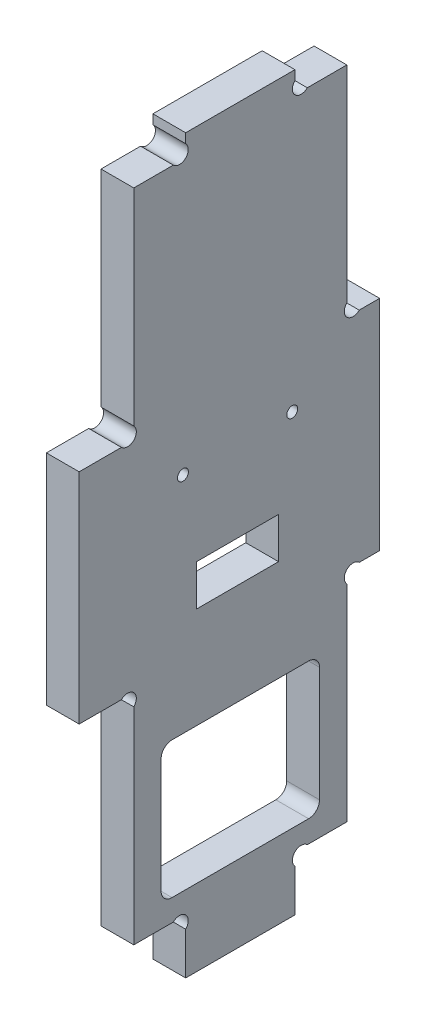
from build123d import *

# Parameters (mm, degrees)
EXTRUSION1_DEPTH        = 6
ESQUISSE2_R             = 1
ESQUISSE2_W             = 29
ESQUISSE2_H             = 25
ENL_V_MAT_EXTRU_1_DEPTH = 7
CONG_1_R                = 2
ESQUISSE3_W             = 15
ESQUISSE3_H             = 7.5
ENL_V_MAT_EXTRU_2_DEPTH = 7


with BuildPart() as part:
    # Esquisse1 → Extrusion1 (new body)
    with BuildSketch(Plane(origin=(0, 0, 0), x_dir=(0, 0, -1), z_dir=(1, 0, 0))):
        with BuildLine():
            Line((19.5, 7.7372583), (19.5, 0))
            Line((19.5, 0), (39.5, 0))
            Line((39.5, 0), (39.5, 7.7372583))
            ThreePointArc((39.5, 7.7372583), (39.5, 10), (41.7627417, 10))
            Line((41.7627417, 10), (49, 10))
            Line((49, 10), (49, 47.7372583))
            ThreePointArc((49, 47.7372583), (49, 50), (51.2627417, 50))
            Line((51.2627417, 50), (55, 50))
            Line((55, 50), (55, 90))
            Line((55, 90), (51.2627417, 90))
            ThreePointArc((51.2627417, 90), (49, 90), (49, 92.2627417))
            Line((49, 92.2627417), (49, 130))
            Line((49, 130), (41.7627417, 130))
            ThreePointArc((41.7627417, 130), (39.5, 130), (39.5, 132.2627417))
            Line((39.5, 132.2627417), (39.5, 134))
            Line((39.5, 134), (19.5, 134))
            Line((19.5, 134), (19.5, 132.2627417))
            ThreePointArc((19.5, 132.2627417), (19.5, 130), (17.2372583, 130))
            Line((17.2372583, 130), (10, 130))
            Line((10, 130), (10, 92.2627417))
            ThreePointArc((10, 92.2627417), (10, 90), (7.7372583, 90))
            Line((7.7372583, 90), (0, 90))
            Line((0, 90), (0, 50))
            Line((0, 50), (7.7372583, 50))
            ThreePointArc((7.7372583, 50), (10, 50), (10, 47.7372583))
            Line((10, 47.7372583), (10, 10))
            Line((10, 10), (17.2372583, 10))
            ThreePointArc((17.2372583, 10), (19.5, 10), (19.5, 7.7372583))
        make_face()
    extrude(amount=EXTRUSION1_DEPTH)

    # Esquisse2 → Enlèv. mat.-Extru.1 (cut, through all)
    with BuildSketch(Plane.ZY):
        with Locations((-39, 80)):
            Circle(ESQUISSE2_R)
        with Locations((-19, 80)):
            Circle(ESQUISSE2_R)
        with Locations((-29.5, 26.5)):
            Rectangle(ESQUISSE2_W, ESQUISSE2_H)
    extrude(amount=-ENL_V_MAT_EXTRU_1_DEPTH, mode=Mode.SUBTRACT)

    # Congé1
    cong_1_edges = [part.edges().sort_by_distance(p)[0] for p in [
        (3, 39, -15),
        (3, 14, -15),
        (3, 14, -44),
        (3, 39, -44),
    ]]
    fillet(cong_1_edges, radius=CONG_1_R)

    # Esquisse3 → Enlèv. mat.-Extru.2 (cut, through all)
    with BuildSketch(Plane.ZY):
        with Locations((-29, 61.25)):
            Rectangle(ESQUISSE3_W, ESQUISSE3_H)
    extrude(amount=-ENL_V_MAT_EXTRU_2_DEPTH, mode=Mode.SUBTRACT)


solid = part.part
